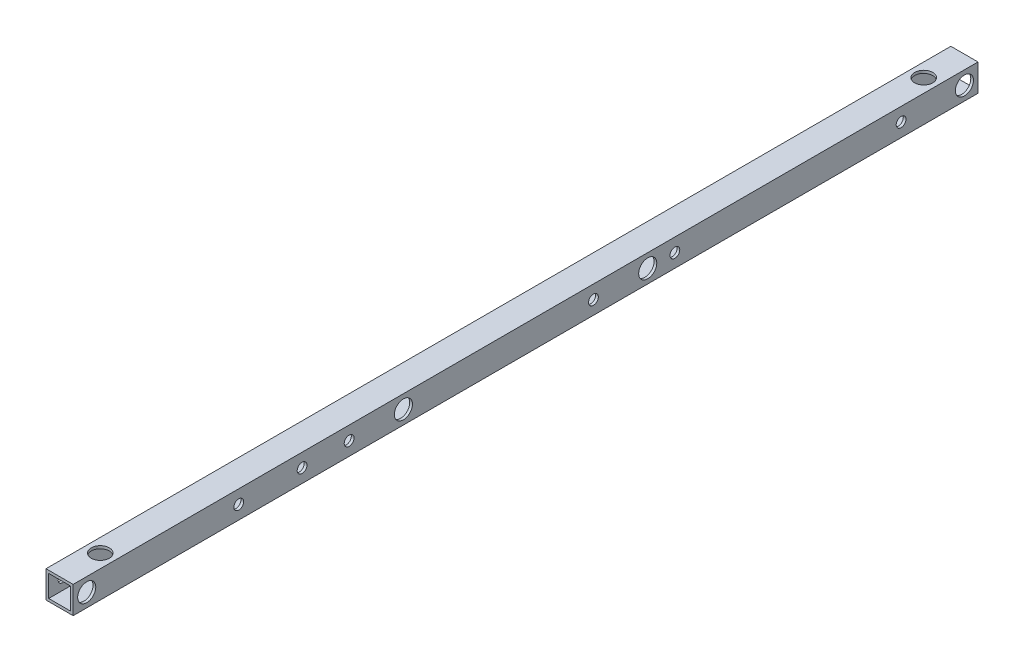
from build123d import *

# Parameters (mm, degrees)
SKETCH_1_W                  = 15
SKETCH_1_H                  = 15
SKETCH_1_W_2                = 12
SKETCH_1_H_2                = 12
EXTRUDE_1_DEPTH             = 500
SKETCH_2_R                  = 2.25
CUT_EXTRUDE_1_DEPTH         = 25
SKETCH_4_R                  = 2.25
CUT_EXTRUDE_3_DEPTH         = 20
SKETCH_5_R                  = 5
CUT_EXTRUDE_4_DEPTH         = 3.3
SKETCH_6_R                  = 5
CUT_EXTRUDE_5_DEPTH         = 3.3
HOLE_WIZARD_5_4_5_4_1_D     = 5.4
HOLE_WIZARD_10_0_10_1_D     = 10
HOLE_WIZARD_10_0_10_1_DEPTH = 1.5
HOLE_WIZARD_10_0_10_1_TIP   = 3.004303095


with BuildPart() as part:
    # ｽｹｯﾁ1 → ﾎﾞｽ - 押し出し1 (new body)
    with BuildSketch(Plane.XY):
        Rectangle(SKETCH_1_W, SKETCH_1_H)
        Rectangle(SKETCH_1_W_2, SKETCH_1_H_2, mode=Mode.SUBTRACT)
    extrude(amount=EXTRUDE_1_DEPTH)

    # ｽｹｯﾁ2 → ｶｯﾄ - 押し出し1 (cut)
    with BuildSketch(Plane(origin=(7.5, 0, 0), x_dir=(0, 0, -1), z_dir=(1, 0, 0))):
        with Locations((-492.5, 0)):
            Circle(SKETCH_2_R)
        with Locations((-7.5, 0)):
            Circle(SKETCH_2_R)
        with Locations((-317.5, 0)):
            Circle(SKETCH_2_R)
        with Locations((-182.5, 0)):
            Circle(SKETCH_2_R)
    extrude(amount=-CUT_EXTRUDE_1_DEPTH, mode=Mode.SUBTRACT)

    # ｽｹｯﾁ4 → ｶｯﾄ - 押し出し3 (cut)
    with BuildSketch(Plane(origin=(0, -7.5, 0), x_dir=(-1, 0, 0), z_dir=(0, -1, 0))):
        with Locations((0, -22.5)):
            Circle(SKETCH_4_R)
        with Locations((0, -477.5)):
            Circle(SKETCH_4_R)
    extrude(amount=-CUT_EXTRUDE_3_DEPTH, mode=Mode.SUBTRACT)

    # ｽｹｯﾁ5 → ｶｯﾄ - 押し出し4 (cut)
    with BuildSketch(Plane(origin=(7.5, 0, 0), x_dir=(0, 0, -1), z_dir=(1, 0, 0))):
        with Locations((-492.5, 0)):
            Circle(SKETCH_5_R)
        with Locations((-7.5, 0)):
            Circle(SKETCH_5_R)
        with Locations((-182.5, 0)):
            Circle(SKETCH_5_R)
        with Locations((-317.5, 0)):
            Circle(SKETCH_5_R)
    extrude(amount=-CUT_EXTRUDE_4_DEPTH, mode=Mode.SUBTRACT)

    # ｽｹｯﾁ6 → ｶｯﾄ - 押し出し5 (cut)
    with BuildSketch(Plane(origin=(0, 7.5, 0), x_dir=(1, 0, 0), z_dir=(0, 1, 0))):
        with Locations((0, -22.5)):
            Circle(SKETCH_6_R)
        with Locations((0, -477.5)):
            Circle(SKETCH_6_R)
    extrude(amount=-CUT_EXTRUDE_5_DEPTH, mode=Mode.SUBTRACT)

    # Ø5.4 (5.4) 直径の穴1 (through all)
    with Locations(Plane(origin=(7.5, 0, 0), x_dir=(0, 0, -1), z_dir=(1, 0, 0))):
        with Locations((-347.5, 0), (-212.5, 0), (-167.5, 0), (-42.5, 0), (-373.5, 0), (-408.5, 0)):
            Hole(HOLE_WIZARD_5_4_5_4_1_D / 2)

    # Ø10.0 (10) 直径の穴1
    with Locations(Plane.ZY.offset(7.5)):
        with Locations((347.5, 0), (212.5, 0), (167.5, 0), (42.5, 0), (373.5, 0), (408.5, 0)):
            Hole(HOLE_WIZARD_10_0_10_1_D / 2, depth=HOLE_WIZARD_10_0_10_1_DEPTH)
            with Locations((0, 0, -(HOLE_WIZARD_10_0_10_1_DEPTH + HOLE_WIZARD_10_0_10_1_TIP / 2))):  # 118° drill point
                Cone(0, HOLE_WIZARD_10_0_10_1_D / 2, HOLE_WIZARD_10_0_10_1_TIP, mode=Mode.SUBTRACT)


solid = part.part
